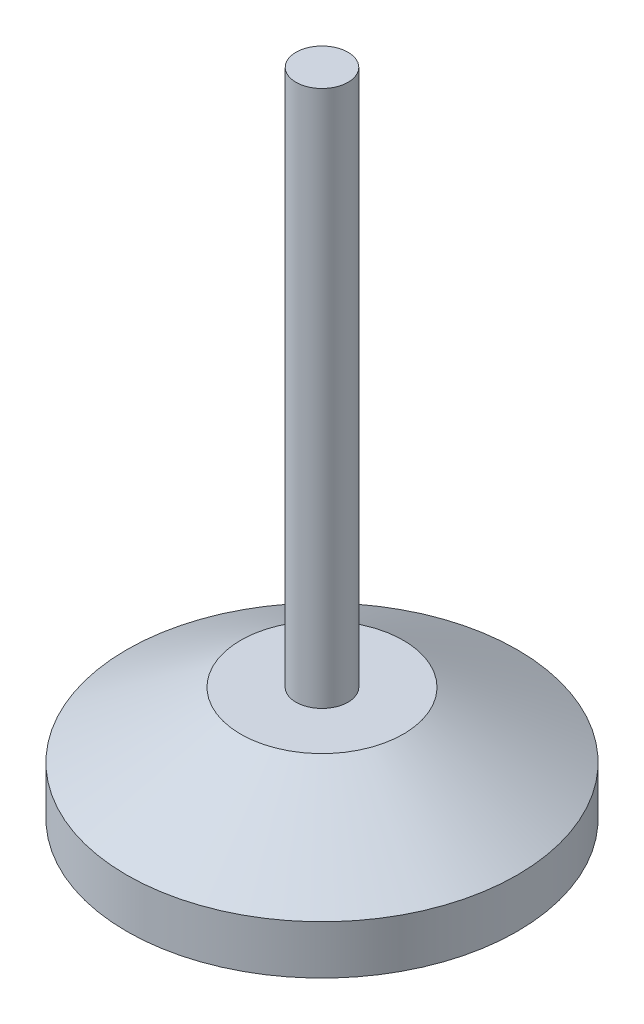
from build123d import *


with BuildPart() as part:
    # 草图1 → 旋转1 (revolve)
    with BuildSketch(Plane.XY):
        Polygon((0, 0), (-60, 0), (-60, 15), (-25, 35), (-8, 35), (-8, 200), (0, 200), align=None)
    revolve(axis=Axis((0, 0, 0), (0, -1, 0)))


solid = part.part
